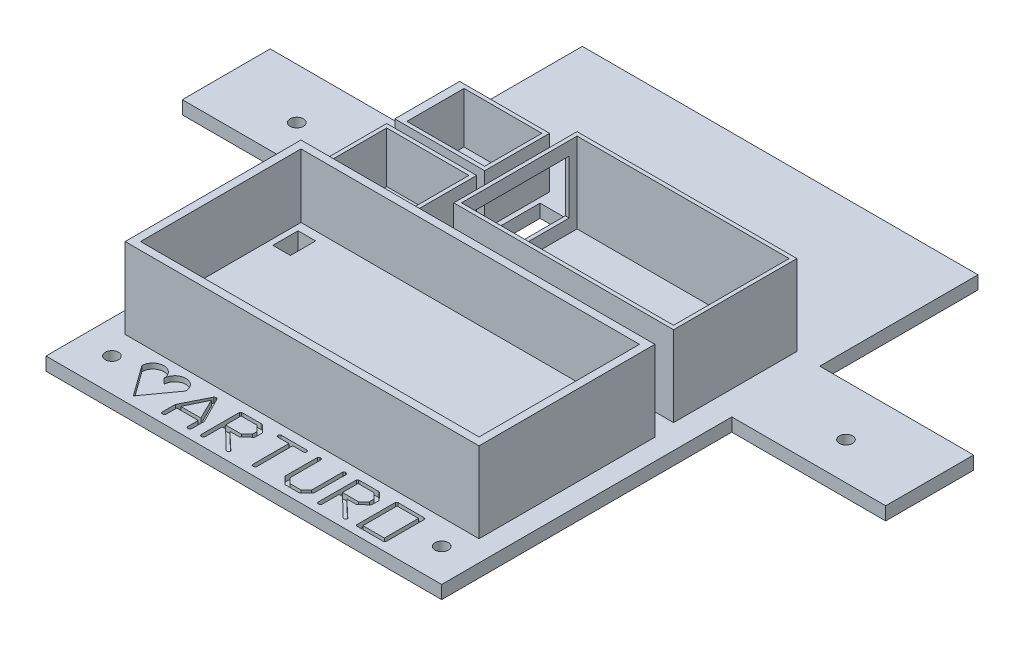
from build123d import *

# Parameters (mm, degrees)
SKETCH1_W           = 90
SKETCH1_H           = 145
BOSS_EXTRUDE1_DEPTH = 3
SKETCH3_W           = 35
SKETCH3_H           = 20
BOSS_EXTRUDE2_DEPTH = 3
SKETCH2_R           = 1.5
CUT_EXTRUDE1_DEPTH  = 3
SKETCH5_W           = 80.5
SKETCH5_H           = 40
BOSS_EXTRUDE3_DEPTH = 18.3
SKETCH7_W           = 77
SKETCH7_H           = 36.5
CUT_EXTRUDE3_DEPTH  = 14.5
SKETCH14_W          = 4
SKETCH14_H          = 5.732043078
CUT_EXTRUDE6_DEPTH  = 192.990234127
SKETCH8_W           = 20.45
SKETCH8_H           = 14.75
BOSS_EXTRUDE4_DEPTH = 11.55
CUT_EXTRUDE4_DEPTH  = 192.994016834
SKETCH12_W          = 9.7
SKETCH12_H          = 8.5
BOSS_EXTRUDE5_DEPTH = 11.55
SKETCH13_W          = 18.7
SKETCH13_H          = 13
SKETCH13_W_2        = 17.7
CUT_EXTRUDE5_DEPTH  = 11.55
SKETCH19_W          = 50
SKETCH19_H          = 28.05
BOSS_EXTRUDE6_DEPTH = 18.3
SKETCH20_W          = 48.25
SKETCH20_H          = 26.3
CUT_EXTRUDE7_DEPTH  = 18.3
SKETCH22_W          = 22.713702628
SKETCH22_H          = 12.207325078
CUT_EXTRUDE8_DEPTH  = 1.75
SKETCH23_W          = 7.3
SKETCH23_H          = 28
CUT_EXTRUDE9_DEPTH  = 193.314560031
SKETCH24_W          = 4.877009242
SKETCH24_H          = 7.758878341
CUT_EXTRUDE10_DEPTH = 1.2
SKETCH25_R          = 1.5
CUT_EXTRUDE11_DEPTH = 193.314560172
SKETCH26_W          = 90
SKETCH26_H          = 23
CUT_EXTRUDE12_DEPTH = 193.314560172


with BuildPart() as part:
    # Sketch1 → Boss-Extrude1 (new body)
    with BuildSketch(Plane(origin=(0, 0, 0), x_dir=(1, 0, 0), z_dir=(0, 1, 0))):
        with Locations((45, 72.5)):
            Rectangle(SKETCH1_W, SKETCH1_H)
    extrude(amount=BOSS_EXTRUDE1_DEPTH)

    # Sketch3 → Boss-Extrude2 (add)
    with BuildSketch(Plane(origin=(0, 3, 0), x_dir=(1, 0, 0), z_dir=(0, 1, 0))):
        with Locations((107.5, 76)):
            Rectangle(SKETCH3_W, SKETCH3_H)
        with Locations((-17.5, 76)):
            Rectangle(SKETCH3_W, SKETCH3_H)
    extrude(amount=-BOSS_EXTRUDE2_DEPTH)

    # Sketch2 → Cut-Extrude1 (cut)
    with BuildSketch(Plane(origin=(0, 3, 0), x_dir=(1, 0, 0), z_dir=(0, 1, 0))):
        with Locations(Location((7.5, 7.5, 0), (0, 0, 270))):
            Circle(SKETCH2_R)
        with Locations(Location((82.5, 7.5, 0), (0, 0, 270))):
            Circle(SKETCH2_R)
    extrude(amount=-CUT_EXTRUDE1_DEPTH, mode=Mode.SUBTRACT)

    # Sketch5 → Boss-Extrude3 (add)
    with BuildSketch(Plane(origin=(0, 3, 0), x_dir=(1, 0, 0), z_dir=(0, 1, 0))):
        with Locations((45, 33.25)):
            Rectangle(SKETCH5_W, SKETCH5_H)
    extrude(amount=BOSS_EXTRUDE3_DEPTH)

    # Sketch7 → Cut-Extrude3 (cut)
    with BuildSketch(Plane(origin=(0, 21.3, 0), x_dir=(1, 0, 0), z_dir=(0, 1, 0))):
        with Locations((45, 33.25)):
            Rectangle(SKETCH7_W, SKETCH7_H)
    extrude(amount=-CUT_EXTRUDE3_DEPTH, mode=Mode.SUBTRACT)

    # Sketch14 → Cut-Extrude6 (cut, through all)
    with BuildSketch(Plane(origin=(0, 6.8, 0), x_dir=(1, 0, 0), z_dir=(0, 1, 0))):
        with Locations((9.802648825, 46.664015238)):
            Rectangle(SKETCH14_W, SKETCH14_H)
    extrude(amount=-CUT_EXTRUDE6_DEPTH, mode=Mode.SUBTRACT)

    # Sketch8 → Boss-Extrude4 (add)
    with BuildSketch(Plane(origin=(0, 3, 0), x_dir=(1, 0, 0), z_dir=(0, 1, 0))):
        with Locations((14.725, 65.625)):
            Rectangle(SKETCH8_W, SKETCH8_H)
        with Locations((14.725, 82.214128063)):
            Rectangle(SKETCH8_W, SKETCH8_H)
    extrude(amount=BOSS_EXTRUDE4_DEPTH)

    # Sketch11 → Cut-Extrude4 (cut, through all)
    with BuildSketch(Plane(origin=(0, 14.55, 0), x_dir=(1, 0, 0), z_dir=(0, 1, 0))):
        with BuildLine():
            Line((23.475, 69.875), (13.775, 69.875))
            ThreePointArc((13.775, 69.875), (9.525, 65.625), (13.775, 61.375))
            Line((13.775, 61.375), (23.475, 61.375))
            Line((23.475, 61.375), (23.475, 69.875))
        make_face()
        with BuildLine():
            Line((23.475, 77.964128063), (13.775, 77.964128063))
            ThreePointArc((13.775, 77.964128063), (9.525, 82.214128063), (13.775, 86.464128063))
            Line((13.775, 86.464128063), (23.475, 86.464128063))
            Line((23.475, 86.464128063), (23.475, 77.964128063))
        make_face()
    extrude(amount=-CUT_EXTRUDE4_DEPTH, mode=Mode.SUBTRACT)

    # Sketch12 → Boss-Extrude5 (add)
    with BuildSketch(Plane(origin=(0, 14.55, 0), x_dir=(1, 0, 0), z_dir=(0, 1, 0))):
        with Locations((18.625, 65.625)):
            Rectangle(SKETCH12_W, SKETCH12_H)
    extrude(amount=-BOSS_EXTRUDE5_DEPTH)

    # Sketch13 → Cut-Extrude5 (cut)
    with BuildSketch(Plane(origin=(0, 14.55, 0), x_dir=(1, 0, 0), z_dir=(0, 1, 0))):
        with Locations((14.725, 65.625)):
            Rectangle(SKETCH13_W, SKETCH13_H)
        with Locations((15.225, 82.214128063)):
            Rectangle(SKETCH13_W_2, SKETCH13_H)
    extrude(amount=-CUT_EXTRUDE5_DEPTH, mode=Mode.SUBTRACT)

    # Sketch19 → Boss-Extrude6 (add)
    with BuildSketch(Plane(origin=(0, 3, 0), x_dir=(1, 0, 0), z_dir=(0, 1, 0))):
        with Locations((59.5, 72.275)):
            Rectangle(SKETCH19_W, SKETCH19_H)
    extrude(amount=BOSS_EXTRUDE6_DEPTH)

    # Sketch20 → Cut-Extrude7 (cut)
    with BuildSketch(Plane(origin=(0, 21.3, 0), x_dir=(1, 0, 0), z_dir=(0, 1, 0))):
        with Locations((59.5, 72.275)):
            Rectangle(SKETCH20_W, SKETCH20_H)
    extrude(amount=-CUT_EXTRUDE7_DEPTH, mode=Mode.SUBTRACT)

    # Sketch22 → Cut-Extrude8 (cut)
    with BuildSketch(Plane.ZY.offset(-34.5)):
        with Locations((-72.275, 12.15)):
            Rectangle(SKETCH22_W, SKETCH22_H)
    extrude(amount=-CUT_EXTRUDE8_DEPTH, mode=Mode.SUBTRACT)

    # Sketch23 → Cut-Extrude9 (cut, through all)
    with BuildSketch(Plane(origin=(0, 3, 0), x_dir=(1, 0, 0), z_dir=(0, 1, 0))):
        with Locations((29.725, 72.3)):
            Rectangle(SKETCH23_W, SKETCH23_H)
    extrude(amount=-CUT_EXTRUDE9_DEPTH, mode=Mode.SUBTRACT)

    # Sketch24 → Cut-Extrude10 (cut)
    with BuildSketch(Plane(origin=(0, 3, 0), x_dir=(1, 0, 0), z_dir=(0, 1, 0))):
        with BuildLine():
            Line((12.8, 9.002960052), (17.8, 2.06645569))
            Line((17.8, 2.06645569), (22.8, 9.002960052))
            ThreePointArc((22.8, 9.002960052), (20.3, 11.502960052), (17.8, 9.002960052))
            ThreePointArc((17.8, 9.002960052), (15.3, 11.502960052), (12.8, 9.002960052))
        make_face()
        with BuildLine():
            Line((27.960572726, 10.919890082), (30.899594276, 5.112854575))
            Line((30.899594276, 5.112854575), (30.899594276, 2.165173562))
            add(Edge.make_bspline(
                [(30.899594276, 2.165173562), (30.892927247, 2.140068414), (30.879954851, 2.091219979), (30.846858341, 2.024032213), (30.800737443, 1.967188076), (30.742020239, 1.921417495), (30.671236475, 1.886557094), (30.588439852, 1.863302375), (30.494943384, 1.847264506), (30.42859556, 1.845629109), (30.39388167, 1.844773452)],
                knots=[0, 0, 0, 0, 0.947643866, 1.843881502, 2.713660738, 3.599912128, 4.543320166, 5.577847846, 6.732704141, 8, 8, 8, 8], degree=3))
            add(Edge.make_bspline(
                [(30.39388167, 1.844773452), (30.344182078, 1.848546499), (30.248653133, 1.855798777), (30.138847489, 1.908146199), (30.070730608, 1.973741423), (30.03673257, 2.042634219), (30.015862164, 2.12641683), (30.013917243, 2.18753699), (30.012865323, 2.220594122)],
                knots=[0, 0, 0, 0, 1.458306385, 2.803050631, 3.475744591, 4.205244022, 5.029297625, 6, 6, 6, 6], degree=3))
            Line((30.012865323, 2.220594122), (30.012865323, 4.615801431))
            Line((30.012865323, 4.615801431), (25.13585608, 4.615801431))
            Line((25.13585608, 4.615801431), (25.132392295, 2.13573139))
            add(Edge.make_bspline(
                [(25.132392295, 2.13573139), (25.1242737, 2.109421365), (25.107472305, 2.054972891), (25.046353025, 1.987225122), (24.967328767, 1.92496232), (24.90233253, 1.895330988), (24.867412745, 1.879411302)],
                knots=[0, 0, 0, 0, 0.85446616, 1.768313713, 2.801007444, 4, 4, 4, 4], degree=3))
            add(Edge.make_bspline(
                [(24.867412745, 1.879411302), (24.856639425, 1.873655896), (24.830690772, 1.859793408), (24.779197205, 1.852562961), (24.713555929, 1.844731283), (24.664262831, 1.84475846), (24.637071044, 1.844773452)],
                knots=[0, 0, 0, 0, 0.618990669, 1.490902888, 2.615894787, 4, 4, 4, 4], degree=3))
            add(Edge.make_bspline(
                [(24.637071044, 1.844773452), (24.609854685, 1.845658545), (24.557815716, 1.847350885), (24.483497085, 1.863312057), (24.416757888, 1.889580371), (24.356389001, 1.925640528), (24.30553323, 1.97679588), (24.273040413, 2.047007647), (24.25207084, 2.131613072), (24.250159634, 2.193881759), (24.249127127, 2.227521692)],
                knots=[0, 0, 0, 0, 1.042871789, 1.994020302, 2.898665572, 3.783582711, 4.676223712, 5.617005175, 6.71261484, 8, 8, 8, 8], degree=3))
            Line((24.249127127, 2.227521692), (24.249127127, 2.362609306))
            Line((24.249127127, 2.362609306), (24.249127127, 5.164811349))
            Line((24.249127127, 5.164811349), (27.182953, 10.975310642))
            add(Edge.make_bspline(
                [(27.182953, 10.975310642), (27.197877117, 10.993849349), (27.229358055, 11.032954903), (27.294231669, 11.082063278), (27.376505657, 11.122430618), (27.437855453, 11.143979663), (27.470447152, 11.155427461)],
                knots=[0, 0, 0, 0, 0.825089278, 1.740443647, 2.79962467, 4, 4, 4, 4], degree=3))
            add(Edge.make_bspline(
                [(27.470447152, 11.155427461), (27.528625563, 11.153661236), (27.636139052, 11.150397258), (27.780169754, 11.104934835), (27.896812425, 11.03137778), (27.93945397, 10.956817158), (27.960572726, 10.919890082)],
                knots=[0, 0, 0, 0, 1.208227024, 2.232799106, 3.124771774, 4, 4, 4, 4], degree=3))
        make_face()
        Polygon((25.262284232, 5.391689265), (29.825820934, 5.391689265), (27.531063389, 10.072994656), align=None, mode=Mode.SUBTRACT)
        with BuildLine():
            Line((38.216840032, 10.992629567), (39.737441636, 9.461636609))
            Line((39.737441636, 9.461636609), (39.766883808, 9.32308521))
            Line((39.766883808, 9.32308521), (39.76168813, 7.800751714))
            Line((39.76168813, 7.800751714), (39.735709743, 7.71415709))
            Line((39.735709743, 7.71415709), (38.111194591, 6.129475464))
            Line((38.111194591, 6.129475464), (37.892976137, 6.05673598))
            Line((37.892976137, 6.05673598), (35.778335411, 6.05673598))
            Line((35.778335411, 6.05673598), (39.720122711, 2.331435241))
            add(Edge.make_bspline(
                [(39.720122711, 2.331435241), (39.731087028, 2.299853317), (39.748714944, 2.249077376), (39.761899762, 2.196987509), (39.766883808, 2.17729681)],
                knots=[0, 0, 0, 0, 1.243971999, 2, 2, 2, 2], degree=3))
            add(Edge.make_bspline(
                [(39.766883808, 2.17729681), (39.766883808, 2.174265998), (39.766883808, 2.170224915), (39.766883808, 2.173111403), (39.766883808, 2.173833025)],
                knots=[0, 0, 0, 0, 1.5, 2, 2, 2, 2], degree=3))
            add(Edge.make_bspline(
                [(39.766883808, 2.173833025), (39.771715245, 2.160766102), (39.780766869, 2.136285421), (39.781815136, 2.097906565), (39.766653287, 2.064033831), (39.7485569, 2.048521029), (39.739173528, 2.040477303)],
                knots=[0, 0, 0, 0, 1.11883269, 2.096116091, 3.012794686, 4, 4, 4, 4], degree=3))
            add(Edge.make_bspline(
                [(39.739173528, 2.040477303), (39.727566205, 2.020510557), (39.70201817, 1.976563202), (39.632985413, 1.925524496), (39.540428519, 1.880986933), (39.468813666, 1.857678145), (39.429164773, 1.844773452)],
                knots=[0, 0, 0, 0, 0.72925176, 1.605103046, 2.67408771, 4, 4, 4, 4], degree=3))
            add(Edge.make_bspline(
                [(39.429164773, 1.844773452), (39.388098016, 1.845041005), (39.313253724, 1.845528621), (39.212689442, 1.858192852), (39.132980278, 1.873757432), (39.091720454, 1.89593355), (39.074126813, 1.905389689)],
                knots=[0, 0, 0, 0, 1.351550787, 2.463205539, 3.344694023, 4, 4, 4, 4], degree=3))
            Line((39.074126813, 1.905389689), (34.806743726, 6.05673598))
            Line((34.806743726, 6.05673598), (34.003145612, 6.05673598))
            Line((34.003145612, 6.05673598), (34.00141372, 2.140927067))
            add(Edge.make_bspline(
                [(34.00141372, 2.140927067), (33.995298712, 2.118873879), (33.981853518, 2.070385079), (33.925548243, 2.005981454), (33.845912839, 1.941976341), (33.780964357, 1.903902874), (33.745093632, 1.882875087)],
                knots=[0, 0, 0, 0, 0.725058933, 1.594202014, 2.671289696, 4, 4, 4, 4], degree=3))
            add(Edge.make_bspline(
                [(33.745093632, 1.882875087), (33.732616994, 1.876419845), (33.704345012, 1.861792309), (33.649847394, 1.854717867), (33.582714396, 1.844008135), (33.532155747, 1.844501964), (33.504360576, 1.844773452)],
                knots=[0, 0, 0, 0, 0.680304615, 1.541565885, 2.648448938, 4, 4, 4, 4], degree=3))
            add(Edge.make_bspline(
                [(33.504360576, 1.844773452), (33.477144217, 1.845658545), (33.425105248, 1.847350885), (33.350786617, 1.863312057), (33.28404742, 1.889580371), (33.223678533, 1.925640528), (33.172822762, 1.97679588), (33.140329944, 2.047007647), (33.119360372, 2.131613072), (33.117449166, 2.193881759), (33.116416659, 2.227521692)],
                knots=[0, 0, 0, 0, 1.042871789, 1.994020302, 2.898665572, 3.783582711, 4.676223712, 5.617005175, 6.71261484, 8, 8, 8, 8], degree=3))
            Line((33.116416659, 2.227521692), (33.116416659, 10.880056555))
            add(Edge.make_bspline(
                [(33.116416659, 10.880056555), (33.127738551, 10.909639319), (33.149713789, 10.967058014), (33.205196118, 11.039896555), (33.277004064, 11.096824962), (33.334391503, 11.117185129), (33.364077285, 11.127717181)],
                knots=[0, 0, 0, 0, 1.036233373, 2.011278177, 2.971259878, 4, 4, 4, 4], degree=3))
            Line((33.364077285, 11.127717181), (33.691404965, 11.143304213))
            Line((33.691404965, 11.143304213), (37.80464962, 11.155427461))
            add(Edge.make_bspline(
                [(37.80464962, 11.155427461), (37.848147953, 11.153572045), (37.929929714, 11.150083653), (38.044855449, 11.120440638), (38.143044379, 11.068947661), (38.192578769, 11.017720115), (38.216840032, 10.992629567)],
                knots=[0, 0, 0, 0, 1.138914518, 2.141287496, 3.08962818, 4, 4, 4, 4], degree=3))
        make_face()
        Polygon((38.880154855, 9.168946778), (37.667830114, 10.379539627), (34.003145612, 10.379539627), (34.003145612, 6.832623814), (37.657438759, 6.832623814), (38.880154855, 8.053608017), align=None, mode=Mode.SUBTRACT)
        with BuildLine():
            add(Edge.make_bspline(
                [(48.197736433, 11.139840428), (48.248814606, 11.129237205), (48.343120312, 11.109660457), (48.463854134, 11.043454426), (48.546553845, 10.945291148), (48.564471284, 10.866382142), (48.573557103, 10.826367888)],
                knots=[0, 0, 0, 0, 1.181692692, 2.181760989, 3.077982587, 4, 4, 4, 4], degree=3))
            add(Edge.make_bspline(
                [(48.573557103, 10.826367888), (48.573025472, 10.798496471), (48.571968338, 10.74307481), (48.549008491, 10.662747651), (48.516655543, 10.585261926), (48.46765368, 10.51200439), (48.39351601, 10.447249055), (48.284248258, 10.408281557), (48.146427953, 10.383035937), (48.043187783, 10.380779691), (47.98644555, 10.379539627)],
                knots=[0, 0, 0, 0, 0.786245999, 1.56343179, 2.346953672, 3.158622924, 4.039912103, 5.081205552, 6.395789976, 8, 8, 8, 8], degree=3))
            Line((47.98644555, 10.379539627), (45.752304242, 10.379539627))
            Line((45.752304242, 10.379539627), (45.752304242, 2.13573139))
            add(Edge.make_bspline(
                [(45.752304242, 2.13573139), (45.737834969, 2.096976441), (45.708739433, 2.019046056), (45.608004208, 1.930437564), (45.473792562, 1.870149939), (45.370273455, 1.853696233), (45.314135443, 1.844773452)],
                knots=[0, 0, 0, 0, 0.875438603, 1.760375598, 2.785460327, 4, 4, 4, 4], degree=3))
            add(Edge.make_bspline(
                [(45.314135443, 1.844773452), (45.282342843, 1.84583333), (45.221893507, 1.847848546), (45.135437701, 1.861253902), (45.058533468, 1.885937494), (44.988796901, 1.918959951), (44.932166785, 1.972224275), (44.891473443, 2.04426098), (44.870524312, 2.135772027), (44.867314145, 2.202025445), (44.865575289, 2.237913047)],
                knots=[0, 0, 0, 0, 1.106735935, 2.104308933, 3.032056499, 3.912699536, 4.765629981, 5.692724586, 6.750214194, 8, 8, 8, 8], degree=3))
            Line((44.865575289, 2.237913047), (44.865575289, 10.379539627))
            Line((44.865575289, 10.379539627), (42.305838193, 10.379539627))
            add(Edge.make_bspline(
                [(42.305838193, 10.379539627), (42.277120088, 10.381743601), (42.219340145, 10.386177929), (42.138420452, 10.42735916), (42.069387205, 10.495113529), (42.033878093, 10.551828043), (42.014880256, 10.582171048)],
                knots=[0, 0, 0, 0, 0.920024065, 1.85106007, 2.850289155, 4, 4, 4, 4], degree=3))
            add(Edge.make_bspline(
                [(42.014880256, 10.582171048), (42.00629867, 10.61489633), (41.990925206, 10.673521966), (41.985918233, 10.733887116), (41.983706191, 10.760555974)],
                knots=[0, 0, 0, 0, 1.116415417, 2, 2, 2, 2], degree=3))
            add(Edge.make_bspline(
                [(41.983706191, 10.760555974), (41.984537517, 10.787221897), (41.986125841, 10.838169579), (42.002598162, 10.909724604), (42.025803592, 10.97430869), (42.063514459, 11.028120753), (42.109238813, 11.074771128), (42.165782125, 11.110765019), (42.231657539, 11.139708174), (42.280159584, 11.149986023), (42.305838193, 11.155427461)],
                knots=[0, 0, 0, 0, 1.135223372, 2.16894787, 3.120179468, 4.042274884, 4.947778528, 5.890363842, 6.883087883, 8, 8, 8, 8], degree=3))
            Line((42.305838193, 11.155427461), (48.197736433, 11.139840428))
        make_face()
        with BuildLine():
            add(Edge.make_bspline(
                [(51.602637062, 11.039390664), (51.623400792, 11.018351255), (51.665842492, 10.975346059), (51.710198178, 10.89002461), (51.732828892, 10.787716362), (51.736029497, 10.714481552), (51.737724676, 10.675693242)],
                knots=[0, 0, 0, 0, 0.882650724, 1.804165135, 2.836991241, 4, 4, 4, 4], degree=3))
            Line((51.737724676, 10.675693242), (51.737724676, 3.787956822))
            Line((51.737724676, 3.787956822), (52.911947782, 2.620661286))
            Line((52.911947782, 2.620661286), (55.40414107, 2.620661286))
            Line((55.40414107, 2.620661286), (56.614733918, 3.834717919))
            Line((56.614733918, 3.834717919), (56.614733918, 10.899107373))
            add(Edge.make_bspline(
                [(56.614733918, 10.899107373), (56.632890994, 10.932991956), (56.667688855, 10.997931434), (56.742769473, 11.077647621), (56.836168491, 11.132180866), (56.906189354, 11.146407269), (56.942061598, 11.153695568)],
                knots=[0, 0, 0, 0, 1.060672957, 2.032769508, 2.992172196, 4, 4, 4, 4], degree=3))
            add(Edge.make_bspline(
                [(56.942061598, 11.153695568), (56.981935287, 11.152266103), (57.057568148, 11.149554677), (57.16653719, 11.131866055), (57.261552996, 11.094021015), (57.347659955, 11.046833201), (57.416735255, 10.978727797), (57.469426213, 10.893284471), (57.495287126, 10.787358437), (57.499320469, 10.712168382), (57.501462872, 10.672229457)],
                knots=[0, 0, 0, 0, 1.13662016, 2.155953935, 3.124124809, 4.037977889, 4.933445915, 5.855694631, 6.861002965, 8, 8, 8, 8], degree=3))
            Line((57.501462872, 10.672229457), (57.451237989, 3.462361035))
            Line((57.451237989, 3.462361035), (55.821527159, 1.867288055))
            Line((55.821527159, 1.867288055), (55.582525996, 1.844773452))
            Line((55.582525996, 1.844773452), (52.539590897, 1.844773452))
            Line((52.539590897, 1.844773452), (52.427017886, 1.920976722))
            Line((52.427017886, 1.920976722), (50.88390168, 3.467556712))
            Line((50.88390168, 3.467556712), (50.850995723, 3.630354606))
            Line((50.850995723, 3.630354606), (50.850995723, 10.892179803))
            add(Edge.make_bspline(
                [(50.850995723, 10.892179803), (50.86578812, 10.927355571), (50.894278256, 10.995104051), (50.968942603, 11.077439753), (51.067054906, 11.13055661), (51.140210444, 11.145769747), (51.178323403, 11.153695568)],
                knots=[0, 0, 0, 0, 1.028909836, 1.981678895, 2.948484413, 4, 4, 4, 4], degree=3))
            add(Edge.make_bspline(
                [(51.178323403, 11.153695568), (51.223443517, 11.152514399), (51.307885706, 11.150303844), (51.42499893, 11.130576304), (51.524113787, 11.094884658), (51.577304562, 11.057293656), (51.602637062, 11.039390664)],
                knots=[0, 0, 0, 0, 1.208192095, 2.261128696, 3.171849697, 4, 4, 4, 4], degree=3))
        make_face()
        with BuildLine():
            Line((64.818708628, 10.992629567), (66.339310231, 9.461636609))
            Line((66.339310231, 9.461636609), (66.368752403, 9.32308521))
            Line((66.368752403, 9.32308521), (66.363556726, 7.800751714))
            Line((66.363556726, 7.800751714), (66.337578339, 7.71415709))
            Line((66.337578339, 7.71415709), (64.713063186, 6.129475464))
            Line((64.713063186, 6.129475464), (64.494844733, 6.05673598))
            Line((64.494844733, 6.05673598), (62.380204007, 6.05673598))
            Line((62.380204007, 6.05673598), (66.321991306, 2.331435241))
            add(Edge.make_bspline(
                [(66.321991306, 2.331435241), (66.332955623, 2.299853317), (66.350583539, 2.249077376), (66.363768357, 2.196987509), (66.368752403, 2.17729681)],
                knots=[0, 0, 0, 0, 1.243971999, 2, 2, 2, 2], degree=3))
            add(Edge.make_bspline(
                [(66.368752403, 2.17729681), (66.368752403, 2.174265998), (66.368752403, 2.170224915), (66.368752403, 2.173111403), (66.368752403, 2.173833025)],
                knots=[0, 0, 0, 0, 1.5, 2, 2, 2, 2], degree=3))
            add(Edge.make_bspline(
                [(66.368752403, 2.173833025), (66.373583841, 2.160766102), (66.382635465, 2.136285421), (66.383683732, 2.097906565), (66.368521883, 2.064033831), (66.350425495, 2.048521029), (66.341042124, 2.040477303)],
                knots=[0, 0, 0, 0, 1.11883269, 2.096116091, 3.012794686, 4, 4, 4, 4], degree=3))
            add(Edge.make_bspline(
                [(66.341042124, 2.040477303), (66.329434801, 2.020510557), (66.303886766, 1.976563202), (66.234854008, 1.925524496), (66.142297114, 1.880986933), (66.070682262, 1.857678145), (66.031033369, 1.844773452)],
                knots=[0, 0, 0, 0, 0.72925176, 1.605103046, 2.67408771, 4, 4, 4, 4], degree=3))
            add(Edge.make_bspline(
                [(66.031033369, 1.844773452), (65.989966612, 1.845041005), (65.915122319, 1.845528621), (65.814558037, 1.858192852), (65.734848874, 1.873757432), (65.693589049, 1.89593355), (65.675995409, 1.905389689)],
                knots=[0, 0, 0, 0, 1.351550787, 2.463205539, 3.344694023, 4, 4, 4, 4], degree=3))
            Line((65.675995409, 1.905389689), (61.408612322, 6.05673598))
            Line((61.408612322, 6.05673598), (60.605014208, 6.05673598))
            Line((60.605014208, 6.05673598), (60.603282315, 2.140927067))
            add(Edge.make_bspline(
                [(60.603282315, 2.140927067), (60.597167307, 2.118873879), (60.583722113, 2.070385079), (60.527416839, 2.005981454), (60.447781435, 1.941976341), (60.382832952, 1.903902874), (60.346962227, 1.882875087)],
                knots=[0, 0, 0, 0, 0.725058933, 1.594202014, 2.671289696, 4, 4, 4, 4], degree=3))
            add(Edge.make_bspline(
                [(60.346962227, 1.882875087), (60.334485589, 1.876419845), (60.306213607, 1.861792309), (60.25171599, 1.854717867), (60.184582991, 1.844008135), (60.134024342, 1.844501964), (60.106229172, 1.844773452)],
                knots=[0, 0, 0, 0, 0.680304615, 1.541565885, 2.648448938, 4, 4, 4, 4], degree=3))
            add(Edge.make_bspline(
                [(60.106229172, 1.844773452), (60.079012812, 1.845658545), (60.026973843, 1.847350885), (59.952655213, 1.863312057), (59.885916015, 1.889580371), (59.825547129, 1.925640528), (59.774691357, 1.97679588), (59.74219854, 2.047007647), (59.721228968, 2.131613072), (59.719317761, 2.193881759), (59.718285255, 2.227521692)],
                knots=[0, 0, 0, 0, 1.042871789, 1.994020302, 2.898665572, 3.783582711, 4.676223712, 5.617005175, 6.71261484, 8, 8, 8, 8], degree=3))
            Line((59.718285255, 2.227521692), (59.718285255, 10.880056555))
            add(Edge.make_bspline(
                [(59.718285255, 10.880056555), (59.729607147, 10.909639319), (59.751582385, 10.967058014), (59.807064714, 11.039896555), (59.878872659, 11.096824962), (59.936260099, 11.117185129), (59.96594588, 11.127717181)],
                knots=[0, 0, 0, 0, 1.036233373, 2.011278177, 2.971259878, 4, 4, 4, 4], degree=3))
            Line((59.96594588, 11.127717181), (60.29327356, 11.143304213))
            Line((60.29327356, 11.143304213), (64.406518216, 11.155427461))
            add(Edge.make_bspline(
                [(64.406518216, 11.155427461), (64.450016548, 11.153572045), (64.531798309, 11.150083653), (64.646724044, 11.120440638), (64.744912975, 11.068947661), (64.794447365, 11.017720115), (64.818708628, 10.992629567)],
                knots=[0, 0, 0, 0, 1.138914518, 2.141287496, 3.08962818, 4, 4, 4, 4], degree=3))
        make_face()
        Polygon((65.48202345, 9.168946778), (64.26969871, 10.379539627), (60.605014208, 10.379539627), (60.605014208, 6.832623814), (64.259307355, 6.832623814), (65.48202345, 8.053608017), align=None, mode=Mode.SUBTRACT)
        with BuildLine():
            add(Edge.make_bspline(
                [(74.872344513, 11.141572321), (74.917954597, 11.130654942), (75.002830944, 11.110338661), (75.113095511, 11.056016493), (75.195226305, 10.979572999), (75.222484374, 10.91542576), (75.236041935, 10.88352034)],
                knots=[0, 0, 0, 0, 1.198848019, 2.230950549, 3.120113869, 4, 4, 4, 4], degree=3))
            Line((75.236041935, 10.88352034), (75.236041935, 10.673961349))
            Line((75.236041935, 10.673961349), (75.23257815, 2.140927067))
            add(Edge.make_bspline(
                [(75.23257815, 2.140927067), (75.224646811, 2.116039226), (75.207750171, 2.063019066), (75.152300742, 1.992187906), (75.075063377, 1.924775524), (75.012241674, 1.88757213), (74.977989955, 1.867288055)],
                knots=[0, 0, 0, 0, 0.810066725, 1.725736988, 2.760023768, 4, 4, 4, 4], degree=3))
            Line((74.977989955, 1.867288055), (74.813460169, 1.844773452))
            Line((74.813460169, 1.844773452), (68.834967304, 1.844773452))
            add(Edge.make_bspline(
                [(68.834967304, 1.844773452), (68.805392619, 1.858600534), (68.74893592, 1.88499579), (68.677051959, 1.943044593), (68.619511242, 2.012591087), (68.596935768, 2.06800907), (68.585574786, 2.095897863)],
                knots=[0, 0, 0, 0, 1.069880941, 2.042352972, 3.014825004, 4, 4, 4, 4], degree=3))
            Line((68.585574786, 2.095897863), (68.585574786, 2.362609306))
            Line((68.585574786, 2.362609306), (68.585574786, 10.892179803))
            add(Edge.make_bspline(
                [(68.585574786, 10.892179803), (68.597620512, 10.922708884), (68.621770589, 10.983915632), (68.693012817, 11.058461124), (68.785264924, 11.118876496), (68.858413187, 11.142737517), (68.897315434, 11.155427461)],
                knots=[0, 0, 0, 0, 0.917586887, 1.839639645, 2.85106129, 4, 4, 4, 4], degree=3))
            Line((68.897315434, 11.155427461), (74.872344513, 11.141572321))
        make_face()
        with Locations((71.910808361, 6.500100457)):
            Rectangle(SKETCH24_W, SKETCH24_H, mode=Mode.SUBTRACT)
    extrude(amount=-CUT_EXTRUDE10_DEPTH, mode=Mode.SUBTRACT)

    # Sketch25 → Cut-Extrude11 (cut, through all)
    with BuildSketch(Plane(origin=(0, 3, 0), x_dir=(1, 0, 0), z_dir=(0, 1, 0))):
        with Locations(Location((-17.46875749, 74.5, 0), (0, 0, 270))):
            Circle(SKETCH25_R)
        with Locations(Location((107.46875749, 74.5, 0), (0, 0, 270))):
            Circle(SKETCH25_R)
    extrude(amount=-CUT_EXTRUDE11_DEPTH, mode=Mode.SUBTRACT)

    # Sketch26 → Cut-Extrude12 (cut, through all)
    with BuildSketch(Plane(origin=(0, 3, 0), x_dir=(1, 0, 0), z_dir=(0, 1, 0))):
        with Locations((45, 133.5)):
            Rectangle(SKETCH26_W, SKETCH26_H)
    extrude(amount=-CUT_EXTRUDE12_DEPTH, mode=Mode.SUBTRACT)


solid = part.part
